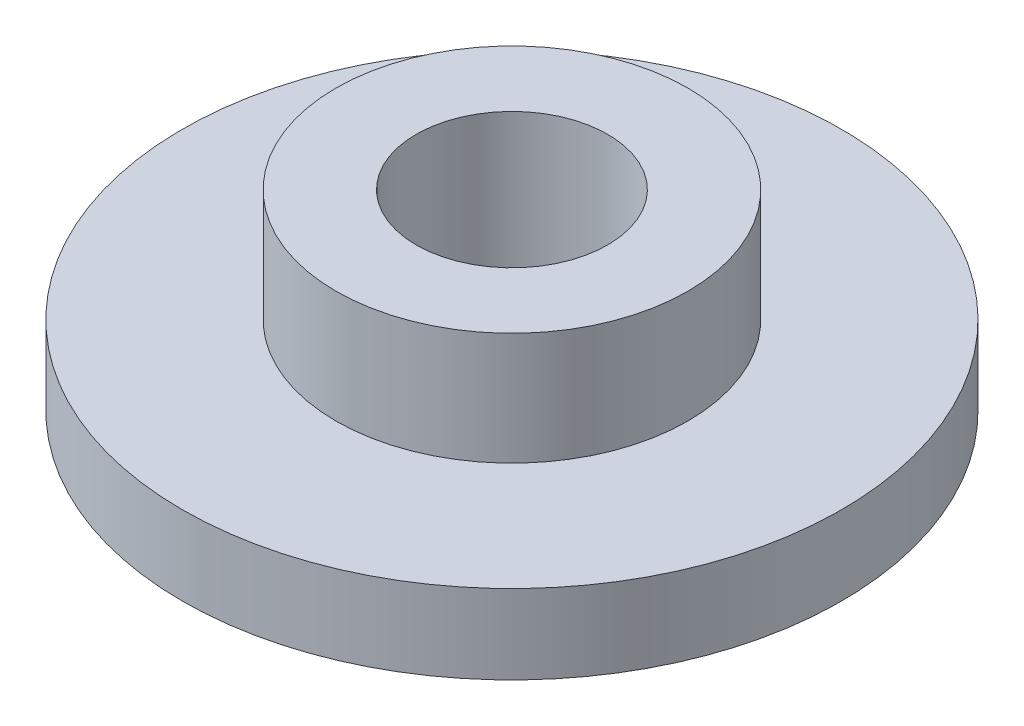
from build123d import *


with BuildPart() as part:
    # Sketch1 → Revolve1 (revolve)
    with BuildSketch(Plane.XY):
        Polygon((-13.759416626, 0), (-4, 0), (-4, 8), (-7.346378674, 8), (-7.346378674, 3.304539552), (-13.759416626, 3.304539552), align=None)
    revolve(axis=Axis((0, 0, 0), (0, -1, 0)))


solid = part.part
